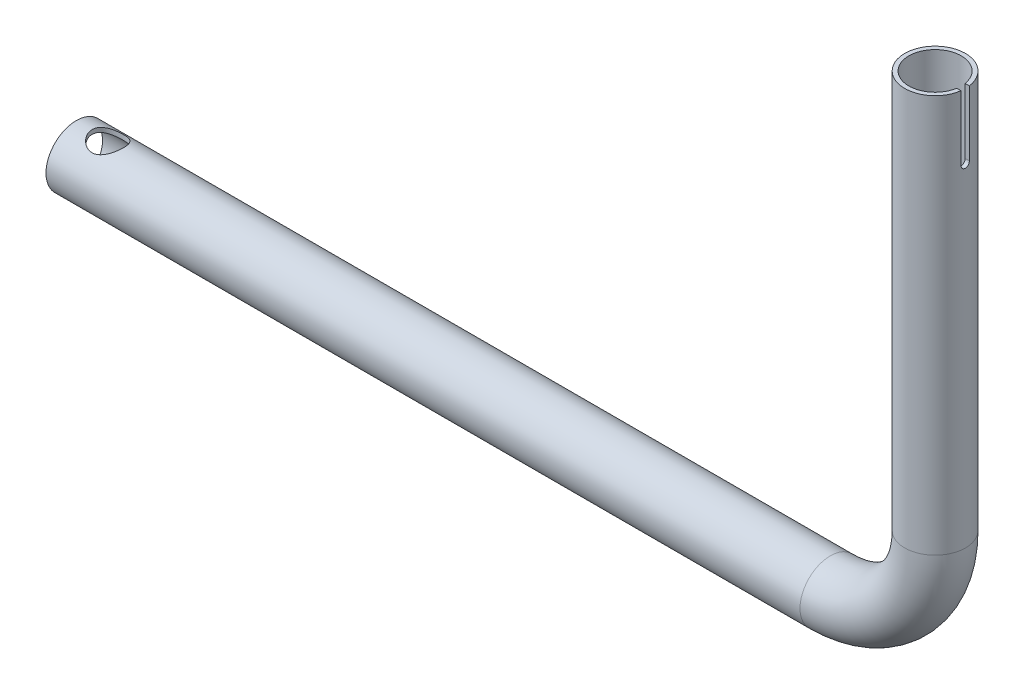
from build123d import *

# Parameters (mm, degrees)
SKETCH_3_R          = 12.5
SHELL_7_T           = 2
CUT_EXTRUDE_4_DEPTH = 476.300168318
SKETCH_19_R         = 7.5
CUT_EXTRUDE_5_DEPTH = 25


with BuildPart() as part:
    # 掃出5: sweep along a path in 草圖1
    with BuildLine(Plane.XY) as sweep_5_path:
        Line((0, 0), (360, 0))
        ThreePointArc((360, 0), (395.355339059, 14.644660941), (410, 50))
        Line((410, 50), (410, 240))
    # 草圖3 → 掃出5 (sweep)
    with BuildSketch(Plane(origin=(60, 240, 0), x_dir=(1, 0, 0), z_dir=(0, 1, 0))):
        with Locations((350, 0)):
            Circle(SKETCH_3_R)
    sweep(path=sweep_5_path.line)

    # 薄殼7
    shell_7_openings = [part.faces().sort_by_distance(p)[0] for p in [
        (0, 0, 0),
        (410, 240, 0),
    ]]
    offset(amount=SHELL_7_T, openings=shell_7_openings, kind=Kind.INTERSECTION)

    # 草圖18 → 除料-伸長4 (cut, through all)
    with BuildSketch(Plane(origin=(410, 0, 0), x_dir=(0, 0, -1), z_dir=(1, 0, 0))):
        with BuildLine():
            Line((-2, 760.068622847), (-2, 240))
            Line((-2, 240), (-2, 209))
            ThreePointArc((-2, 209), (0, 207), (2, 209))
            Line((2, 209), (2, 240))
            Line((2, 240), (2, 760.068622847))
            Line((2, 760.068622847), (2, 1800.205868541))
            Line((2, 1800.205868541), (-2, 1800.205868541))
            Line((-2, 1800.205868541), (-2, 760.068622847))
        make_face()
    extrude(amount=CUT_EXTRUDE_4_DEPTH, mode=Mode.SUBTRACT)

    # 草圖19 → 除料-伸長5 (cut, symmetric)
    with BuildSketch(Plane(origin=(0, 0, 0), x_dir=(1, 0, 0), z_dir=(0, 1, 0))):
        with Locations(Location((15, 0, 0), (0, 0, 270))):
            Circle(SKETCH_19_R)
    extrude(amount=CUT_EXTRUDE_5_DEPTH, both=True, mode=Mode.SUBTRACT)


solid = part.part
